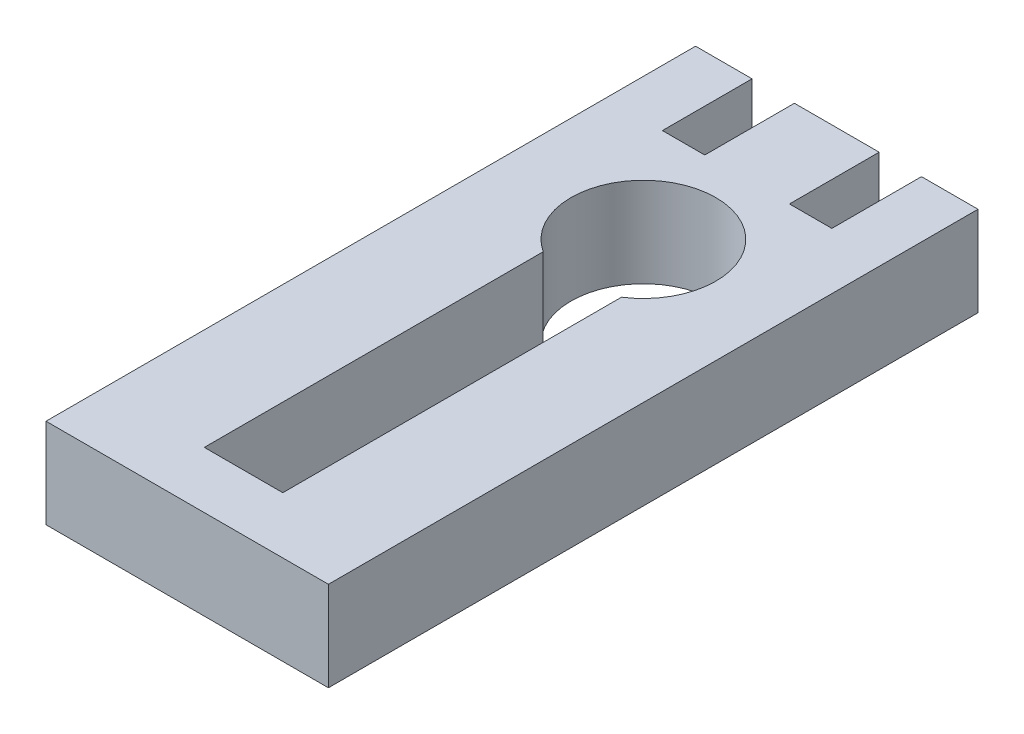
from build123d import *

# Parameters (mm, degrees)
BOSS_EXTRUDE1_DEPTH = 3.175
CUT_EXTRUDE1_REACH  = 5.175


with BuildPart() as part:
    # Sketch1 → Boss-Extrude1 (new body)
    with BuildSketch(Plane(origin=(0, 0, 0), x_dir=(1, 0, 0), z_dir=(0, 1, 0))):
        Polygon((0, 0), (10, 0), (10, 23), (8, 23), (8, 19.825), (6.5, 19.825), (6.5, 23), (3.5, 23), (3.5, 19.825), (2, 19.825), (2, 23), (0, 23), align=None)
    extrude(amount=BOSS_EXTRUDE1_DEPTH)

    # Sketch3 → Cut-Extrude1 (cut, up to next)
    with BuildSketch(Plane(origin=(0, 3.175, 0), x_dir=(1, 0, 0), z_dir=(0, 1, 0)), mode=Mode.PRIVATE) as cut_extrude1_sk1:
        with BuildLine():
            Line((3.605, 2), (6.385, 2))
            Line((6.385, 2), (6.385, 13.993552011))
            ThreePointArc((6.385, 13.993552011), (5.005949297, 18.717480034), (3.605, 14))
            Line((3.605, 14), (3.605, 2))
        make_face()
    cut_extrude1_tool1 = extrude(cut_extrude1_sk1.sketch, amount=-CUT_EXTRUDE1_REACH, mode=Mode.PRIVATE) & part.part
    add(cut_extrude1_tool1.solids().sort_by_distance((4.996868, 3.175, -11.078992))[0], mode=Mode.SUBTRACT)


solid = part.part
